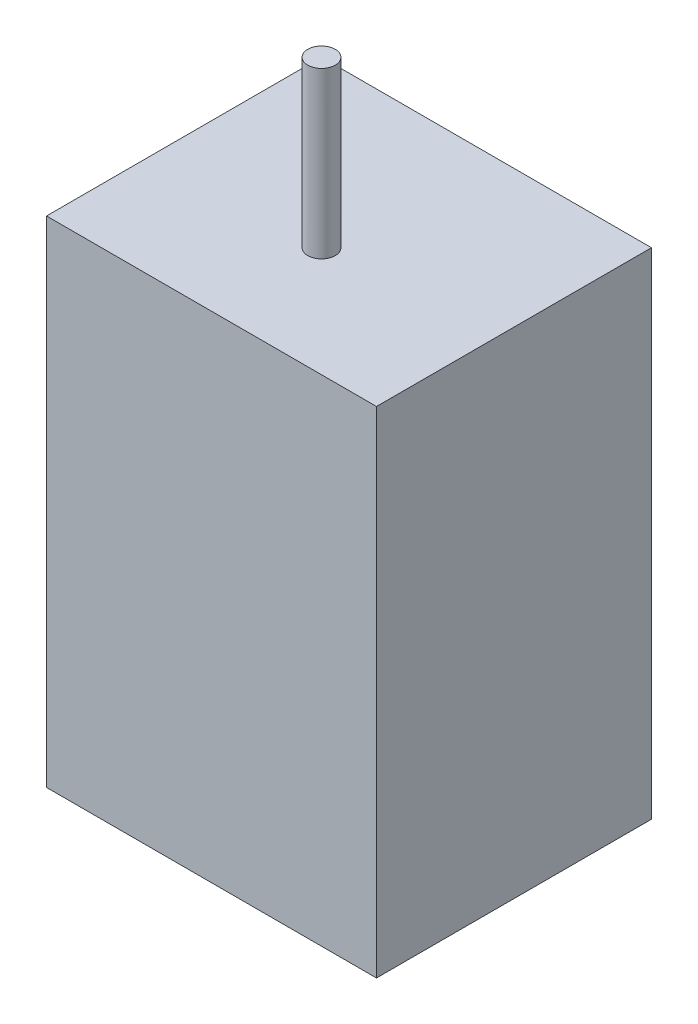
from build123d import *

# Parameters (mm, degrees)
SKETCH1_W           = 19.05
SKETCH1_H           = 15.875
BOSS_EXTRUDE1_DEPTH = 28.575
BOSS_EXTRUDE2_DEPTH = 9.525


with BuildPart() as part:
    # Sketch1 → Boss-Extrude1 (new body)
    with BuildSketch(Plane(origin=(0, 0, 0), x_dir=(1, 0, 0), z_dir=(0, 1, 0))):
        with Locations((9.525, 7.9375)):
            Rectangle(SKETCH1_W, SKETCH1_H)
    extrude(amount=BOSS_EXTRUDE1_DEPTH)

    # Sketch2 → Boss-Extrude2 (add)
    with BuildSketch(Plane(origin=(0, 28.575, 0), x_dir=(1, 0, 0), z_dir=(0, 1, 0))):
        with BuildLine():
            ThreePointArc((10.31875, 6.35), (9.525, 7.14375), (8.73125, 6.35))
            Line((8.73125, 6.35), (10.31875, 6.35))
        make_face()
        with BuildLine():
            Line((10.31875, 6.35), (8.73125, 6.35))
            ThreePointArc((8.73125, 6.35), (9.525, 5.55625), (10.31875, 6.35))
        make_face()
    extrude(amount=BOSS_EXTRUDE2_DEPTH)


solid = part.part
